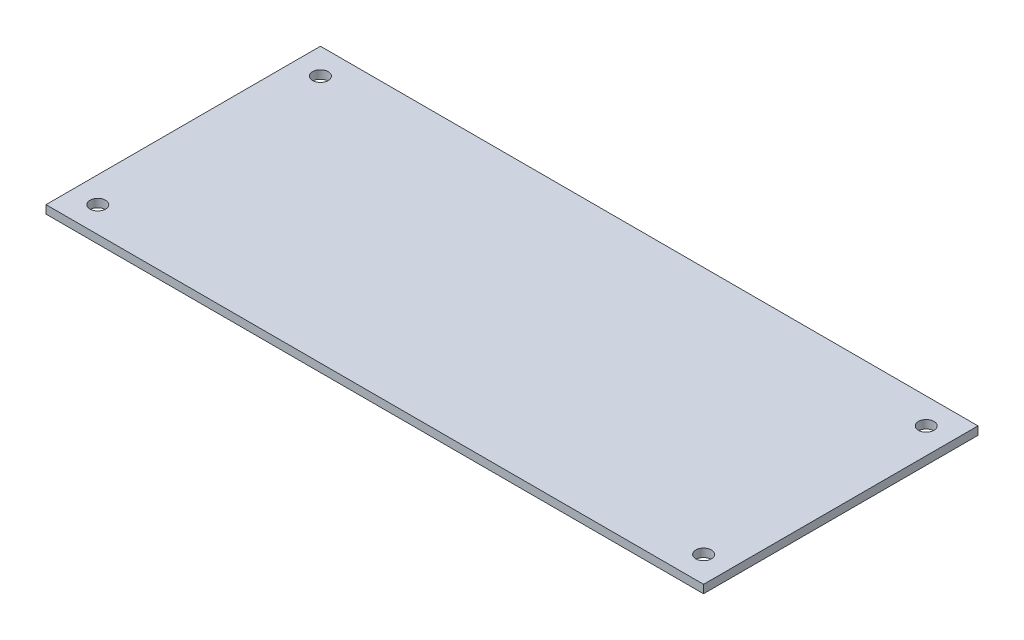
from build123d import *

# Parameters (mm, degrees)
SKETCH1_W           = 127
SKETCH1_H           = 53
BOSS_EXTRUDE1_DEPTH = 1.5875
SKETCH2_R           = 1.5
CUT_EXTRUDE1_DEPTH  = 2.5875


with BuildPart() as part:
    # Sketch1 → Boss-Extrude1 (new body)
    with BuildSketch(Plane(origin=(0, 0, 0), x_dir=(1, 0, 0), z_dir=(0, 1, 0))):
        Rectangle(SKETCH1_W, SKETCH1_H)
    extrude(amount=BOSS_EXTRUDE1_DEPTH)

    # Sketch2 → Cut-Extrude1 (cut, through all)
    with BuildSketch(Plane(origin=(0, 1.5875, 0), x_dir=(1, 0, 0), z_dir=(0, 1, 0))):
        with Locations((-58.5, -21.5)):
            Circle(SKETCH2_R)
        with Locations((58.5, -21.5)):
            Circle(SKETCH2_R)
        with Locations((58.5, 21.5)):
            Circle(SKETCH2_R)
        with Locations((-58.5, 21.5)):
            Circle(SKETCH2_R)
    extrude(amount=-CUT_EXTRUDE1_DEPTH, mode=Mode.SUBTRACT)


solid = part.part
